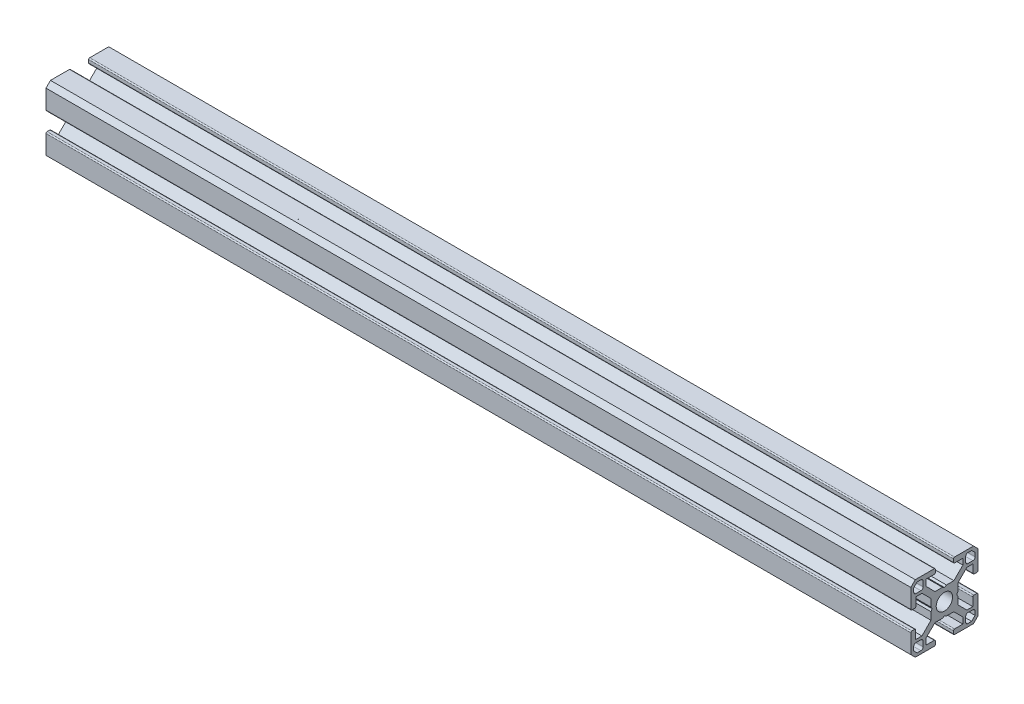
from build123d import *

# Parameters (mm, degrees)
SKETCH1_R          = 3.65
MAIN_EXTRUDE_DEPTH = 193.04


with BuildPart() as part:
    # Sketch1 → main Extrude (new body, symmetric)
    with BuildSketch(Plane(origin=(0, 0, 0), x_dir=(0, -1, 0), z_dir=(-1, 0, 0))):
        with BuildLine():
            Line((4.549996167, -15), (12.999943754, -15))
            Line((12.999943754, -15), (15, -12.999944234))
            Line((15, -12.999944234), (15, -4.54998765))
            ThreePointArc((15, -4.54998765), (14.853553391, -4.19643426), (14.5, -4.04998765))
            Line((14.5, -4.04998765), (13.299974565, -4.04998765))
            ThreePointArc((13.299974565, -4.04998765), (12.946421174, -4.19643426), (12.799974565, -4.54998765))
            Line((12.799974565, -4.54998765), (12.799974565, -8.249978163))
            Line((12.799974565, -8.249978163), (10.04886106, -8.249978163))
            Line((10.04886106, -8.249978163), (5.999989561, -4.201106482))
            Line((5.999989561, -4.201106482), (5.999989561, -0.899233628))
            Line((5.999989561, -0.899233628), (5.484990531, 5.429e-06))
            Line((5.484990531, 5.429e-06), (5.999989561, 0.899244177))
            Line((5.999989561, 0.899244177), (5.999989561, 4.232229952))
            Line((5.999989561, 4.232229952), (10.017749022, 8.249988862))
            Line((10.017749022, 8.249988862), (12.681560202, 8.249988862))
            Line((12.681560202, 8.249988862), (12.681560202, 4.549996167))
            ThreePointArc((12.681560202, 4.549996167), (12.828006812, 4.196442776), (13.181560202, 4.049996167))
            Line((13.181560202, 4.049996167), (14.5, 4.049996167))
            ThreePointArc((14.5, 4.049996167), (14.853553391, 4.196442776), (15, 4.549996167))
            Line((15, 4.549996167), (15, 12.999943159))
            Line((15, 12.999943159), (12.999943639, 15))
            Line((12.999943639, 15), (4.54998765, 15))
            ThreePointArc((4.54998765, 15), (4.19643426, 14.853553391), (4.04998765, 14.5))
            Line((4.04998765, 14.5), (4.04998765, 13.299974565))
            ThreePointArc((4.04998765, 13.299974565), (4.19643426, 12.946421174), (4.54998765, 12.799974565))
            Line((4.54998765, 12.799974565), (8.249978163, 12.799974565))
            Line((8.249978163, 12.799974565), (8.249978163, 10.04886106))
            Line((8.249978163, 10.04886106), (4.201106482, 5.999989561))
            Line((4.201106482, 5.999989561), (0.899233628, 5.999989561))
            Line((0.899233628, 5.999989561), (-5.358e-06, 5.484990655))
            Line((-5.358e-06, 5.484990655), (-0.899244177, 5.999989561))
            Line((-0.899244177, 5.999989561), (-4.232229952, 5.999989561))
            Line((-4.232229952, 5.999989561), (-8.249988862, 10.017749022))
            Line((-8.249988862, 10.017749022), (-8.249988862, 12.681560202))
            Line((-8.249988862, 12.681560202), (-4.549996167, 12.681560202))
            ThreePointArc((-4.549996167, 12.681560202), (-4.196442776, 12.828006812), (-4.049996167, 13.181560202))
            Line((-4.049996167, 13.181560202), (-4.049996167, 14.5))
            ThreePointArc((-4.049996167, 14.5), (-4.196442776, 14.853553391), (-4.549996167, 15))
            Line((-4.549996167, 15), (-12.999943355, 15))
            Line((-12.999943355, 15), (-15, 12.999943836))
            Line((-15, 12.999943836), (-15, 4.54998765))
            ThreePointArc((-15, 4.54998765), (-14.853553391, 4.19643426), (-14.5, 4.04998765))
            Line((-14.5, 4.04998765), (-13.299974565, 4.04998765))
            ThreePointArc((-13.299974565, 4.04998765), (-12.946421174, 4.19643426), (-12.799974565, 4.54998765))
            Line((-12.799974565, 4.54998765), (-12.799974565, 8.249978163))
            Line((-12.799974565, 8.249978163), (-10.048860846, 8.249978163))
            Line((-10.048860846, 8.249978163), (-5.999989347, 4.201106482))
            Line((-5.999989347, 4.201106482), (-5.999989347, 0.899233628))
            Line((-5.999989347, 0.899233628), (-5.484990531, -5.429e-06))
            Line((-5.484990531, -5.429e-06), (-5.999989347, -0.899244177))
            Line((-5.999989347, -0.899244177), (-5.999989347, -4.232229952))
            Line((-5.999989347, -4.232229952), (-10.017748808, -8.249988862))
            Line((-10.017748808, -8.249988862), (-12.681560202, -8.249988862))
            Line((-12.681560202, -8.249988862), (-12.681560202, -4.549996167))
            ThreePointArc((-12.681560202, -4.549996167), (-12.828006812, -4.196442776), (-13.181560202, -4.049996167))
            Line((-13.181560202, -4.049996167), (-14.5, -4.049996167))
            ThreePointArc((-14.5, -4.049996167), (-14.853553391, -4.196442776), (-15, -4.549996167))
            Line((-15, -4.549996167), (-15, -12.999948112))
            Line((-15, -12.999948112), (-12.999947631, -15))
            Line((-12.999947631, -15), (-4.54998765, -15))
            ThreePointArc((-4.54998765, -15), (-4.19643426, -14.853553391), (-4.04998765, -14.5))
            Line((-4.04998765, -14.5), (-4.04998765, -13.299974565))
            ThreePointArc((-4.04998765, -13.299974565), (-4.19643426, -12.946421174), (-4.54998765, -12.799974565))
            Line((-4.54998765, -12.799974565), (-8.249978163, -12.799974565))
            Line((-8.249978163, -12.799974565), (-8.249978163, -10.048860449))
            Line((-8.249978163, -10.048860449), (-4.201106482, -5.999988951))
            Line((-4.201106482, -5.999988951), (-0.899233628, -5.999988951))
            Line((-0.899233628, -5.999988951), (5.367e-06, -5.484990026))
            Line((5.367e-06, -5.484990026), (0.899244177, -5.999988951))
            Line((0.899244177, -5.999988951), (4.232229952, -5.999988951))
            Line((4.232229952, -5.999988951), (8.249988862, -10.017748412))
            Line((8.249988862, -10.017748412), (8.249988862, -12.681560202))
            Line((8.249988862, -12.681560202), (4.549996167, -12.681560202))
            ThreePointArc((4.549996167, -12.681560202), (4.196442776, -12.828006812), (4.049996167, -13.181560202))
            Line((4.049996167, -13.181560202), (4.049996167, -14.5))
            ThreePointArc((4.049996167, -14.5), (4.196442776, -14.853553391), (4.549996167, -15))
        make_face()
        Circle(SKETCH1_R, mode=Mode.SUBTRACT)
        with BuildLine():
            Line((-10.499978684, 9.499980695), (-12.6999746, 9.499980695))
            ThreePointArc((-12.6999746, 9.499980695), (-13.407079967, 9.792873328), (-13.6999726, 10.499978695))
            Line((-13.6999726, 10.499978695), (-13.6999726, 12.178655581))
            Line((-13.6999726, 12.178655581), (-12.178655571, 13.69997261))
            Line((-12.178655571, 13.69997261), (-10.499978695, 13.69997261))
            ThreePointArc((-10.499978695, 13.69997261), (-9.79287332, 13.407079974), (-9.499980684, 12.6999746))
            Line((-9.499980684, 12.6999746), (-9.499980684, 10.499978695))
            ThreePointArc((-9.499980684, 10.499978695), (-9.792873317, 9.792873328), (-10.499978684, 9.499980695))
        make_face(mode=Mode.SUBTRACT)
        with BuildLine():
            Line((9.499981, 10.499978695), (9.499981, 12.69997461))
            ThreePointArc((9.499981, 12.69997461), (9.792873633, 13.407079977), (10.499979, 13.69997261))
            Line((10.499979, 13.69997261), (12.178655581, 13.69997261))
            Line((12.178655581, 13.69997261), (13.69997261, 12.178655581))
            Line((13.69997261, 12.178655581), (13.69997261, 10.499978705))
            ThreePointArc((13.69997261, 10.499978705), (13.407079974, 9.792873331), (12.6999746, 9.499980695))
            Line((12.6999746, 9.499980695), (10.499979, 9.499980695))
            ThreePointArc((10.499979, 9.499980695), (9.792873633, 9.792873328), (9.499981, 10.499978695))
        make_face(mode=Mode.SUBTRACT)
        with BuildLine():
            Line((10.499979, -9.49998099), (12.69997461, -9.49998099))
            ThreePointArc((12.69997461, -9.49998099), (13.407079977, -9.792873623), (13.69997261, -10.49997899))
            Line((13.69997261, -10.49997899), (13.69997261, -12.178655571))
            Line((13.69997261, -12.178655571), (12.178655581, -13.6999726))
            Line((12.178655581, -13.6999726), (10.49997901, -13.6999726))
            ThreePointArc((10.49997901, -13.6999726), (9.792873636, -13.407079964), (9.499981, -12.69997459))
            Line((9.499981, -12.69997459), (9.499981, -10.49997899))
            ThreePointArc((9.499981, -10.49997899), (9.792873633, -9.792873623), (10.499979, -9.49998099))
        make_face(mode=Mode.SUBTRACT)
        with BuildLine():
            Line((-9.499980684, -10.49997899), (-9.499980684, -12.6999746))
            ThreePointArc((-9.499980684, -12.6999746), (-9.792873317, -13.407079967), (-10.499978684, -13.6999726))
            Line((-10.499978684, -13.6999726), (-12.178655571, -13.6999726))
            Line((-12.178655571, -13.6999726), (-13.6999726, -12.178655571))
            Line((-13.6999726, -12.178655571), (-13.6999726, -10.499979))
            ThreePointArc((-13.6999726, -10.499979), (-13.407079964, -9.792873626), (-12.69997459, -9.49998099))
            Line((-12.69997459, -9.49998099), (-10.499978684, -9.49998099))
            ThreePointArc((-10.499978684, -9.49998099), (-9.792873317, -9.792873623), (-9.499980684, -10.49997899))
        make_face(mode=Mode.SUBTRACT)
    extrude(amount=MAIN_EXTRUDE_DEPTH, both=True)


solid = part.part
